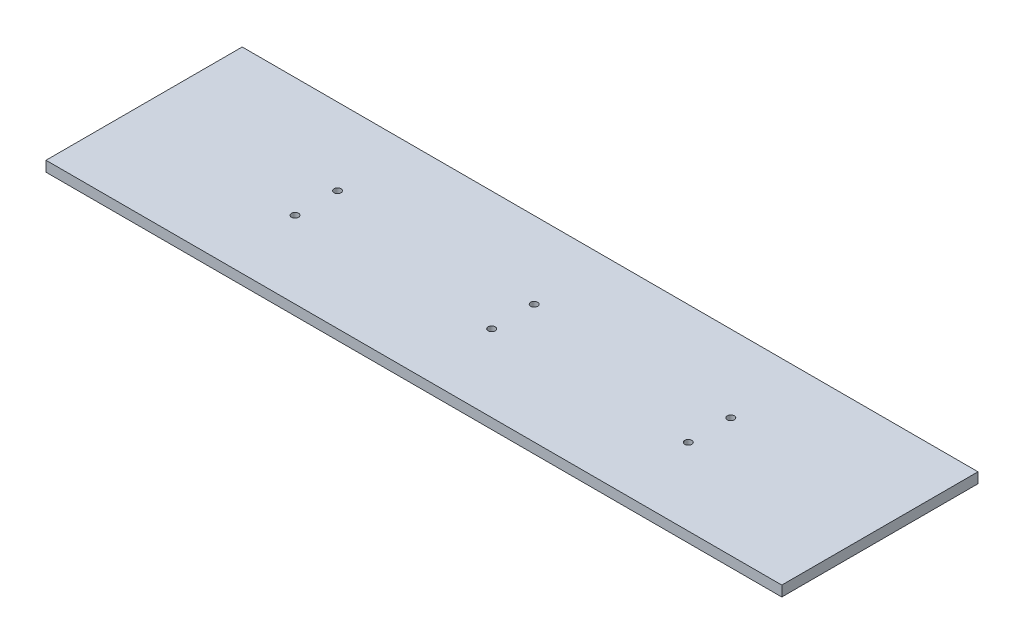
from build123d import *

# Parameters (mm, degrees)
SKETCH1_W           = 450
SKETCH1_H           = 120
SKETCH1_R           = 2.16
BOSS_EXTRUDE1_DEPTH = 6.35


with BuildPart() as part:
    # Sketch1 → Boss-Extrude1 (new body)
    with BuildSketch(Plane(origin=(0, 0, 0), x_dir=(1, 0, 0), z_dir=(0, 1, 0))):
        with Locations((225, 60)):
            Rectangle(SKETCH1_W, SKETCH1_H)
        with Locations((345.81, 47)):
            Circle(SKETCH1_R, mode=Mode.SUBTRACT)
        with Locations((225.56, 47)):
            Circle(SKETCH1_R, mode=Mode.SUBTRACT)
        with Locations((105.31, 47)):
            Circle(SKETCH1_R, mode=Mode.SUBTRACT)
        with Locations((105.31, 73)):
            Circle(SKETCH1_R, mode=Mode.SUBTRACT)
        with Locations((225.56, 73)):
            Circle(SKETCH1_R, mode=Mode.SUBTRACT)
        with Locations((345.81, 73)):
            Circle(SKETCH1_R, mode=Mode.SUBTRACT)
    extrude(amount=BOSS_EXTRUDE1_DEPTH)


solid = part.part
